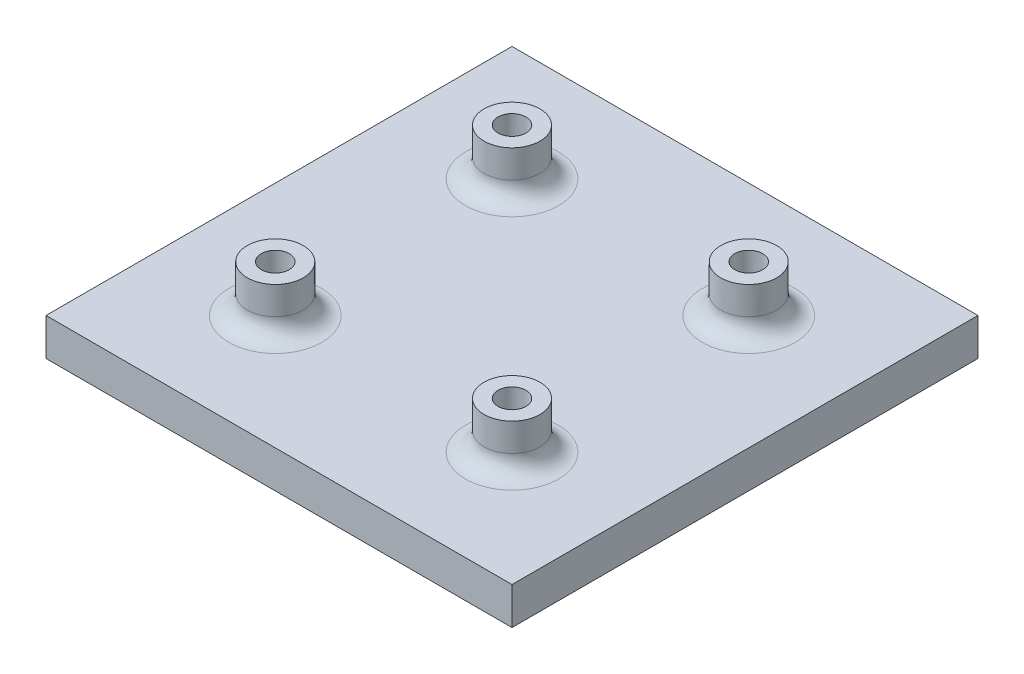
from build123d import *

# Parameters (mm, degrees)
SKETCH2_W                 = 50
SKETCH2_H                 = 50
BOSS_EXTRUDE1_DEPTH       = 4
SKETCH3_R                 = 1.5
CUT_EXTRUDE1_DEPTH        = 4
BOSS_EXTRUDE2_START       = 5
SKETCH4_R                 = 3
SKETCH4_R_2               = 1.5
BOSS_EXTRUDE2_DEPTH       = 5
MIRROR2_START             = 5
MIRROR2_COPY_1_SKETCH_R   = 3
MIRROR2_COPY_1_SKETCH_R_2 = 1.5
MIRROR2_COPY_1_DEPTH      = 5
FILLET1_R                 = 2
SKETCH6_W                 = 50
SKETCH6_H                 = 50
BOSS_EXTRUDE3_DEPTH       = 4


with BuildPart() as part:
    # Sketch2 → Boss-Extrude1 (new body)
    with BuildSketch(Plane(origin=(0, 0, 0), x_dir=(1, 0, 0), z_dir=(0, 1, 0))):
        with Locations((25, 25)):
            Rectangle(SKETCH2_W, SKETCH2_H)
    extrude(amount=BOSS_EXTRUDE1_DEPTH)

    # Sketch3 → Cut-Extrude1 (cut)
    with BuildSketch(Plane(origin=(0, 4, 0), x_dir=(1, 0, 0), z_dir=(0, 1, 0))):
        with Locations(Location((12.3, 37.7, 0), (0, 0, 270))):
            Circle(SKETCH3_R)
        with Locations(Location((12.3, 12.3, 0), (0, 0, 270))):
            Circle(SKETCH3_R)
        with Locations(Location((37.7, 37.7, 0), (0, 0, 270))):
            Circle(SKETCH3_R)
        with Locations(Location((37.7, 12.3, 0), (0, 0, 270))):
            Circle(SKETCH3_R)
    extrude(amount=-CUT_EXTRUDE1_DEPTH, mode=Mode.SUBTRACT)

    # Sketch4 → Boss-Extrude2 (add)
    with BuildSketch(Plane(origin=(0, 4, 0), x_dir=(1, 0, 0), z_dir=(0, 1, 0)).offset(BOSS_EXTRUDE2_START)):
        with Locations(Location((12.3, 37.7, 0), (0, 0, 90))):
            Circle(SKETCH4_R)
        with Locations(Location((12.3, 37.7, 0), (0, 0, 270))):
            Circle(SKETCH4_R_2, mode=Mode.SUBTRACT)
    boss_extrude2 = extrude(amount=-BOSS_EXTRUDE2_DEPTH)

    # Mirror1: Boss-Extrude2 across plane
    add(boss_extrude2.mirror(Plane.XY.offset(-25)))

    # Mirror2: Boss-Extrude2 across plane
    add(boss_extrude2.mirror(Plane.ZY.offset(-25)))

    # Mirror2 copy 1 sketch → Mirror2 copy 1 (add)
    with BuildSketch(Plane(origin=(50, 4, -50), x_dir=(-1, 0, 0), z_dir=(0, 1, 0)).offset(MIRROR2_START)):
        with Locations(Location((12.3, 37.7, 0), (0, 0, 90))):
            Circle(MIRROR2_COPY_1_SKETCH_R)
        with Locations(Location((12.3, 37.7, 0), (0, 0, 270))):
            Circle(MIRROR2_COPY_1_SKETCH_R_2, mode=Mode.SUBTRACT)
    extrude(amount=-MIRROR2_COPY_1_DEPTH)

    # Fillet1
    fillet1_edges = [part.edges().sort_by_distance(p)[0] for p in [
        (12.3, 4, -34.7),
        (12.3, 4, -15.3),
        (37.7, 4, -15.3),
        (37.7, 4, -34.7),
    ]]
    fillet(fillet1_edges, radius=FILLET1_R)

    # Sketch6 → Boss-Extrude3 (add)
    with BuildSketch(Plane.XZ):
        with Locations((25, -25)):
            Rectangle(SKETCH6_W, SKETCH6_H)
    extrude(amount=-BOSS_EXTRUDE3_DEPTH)


solid = part.part
